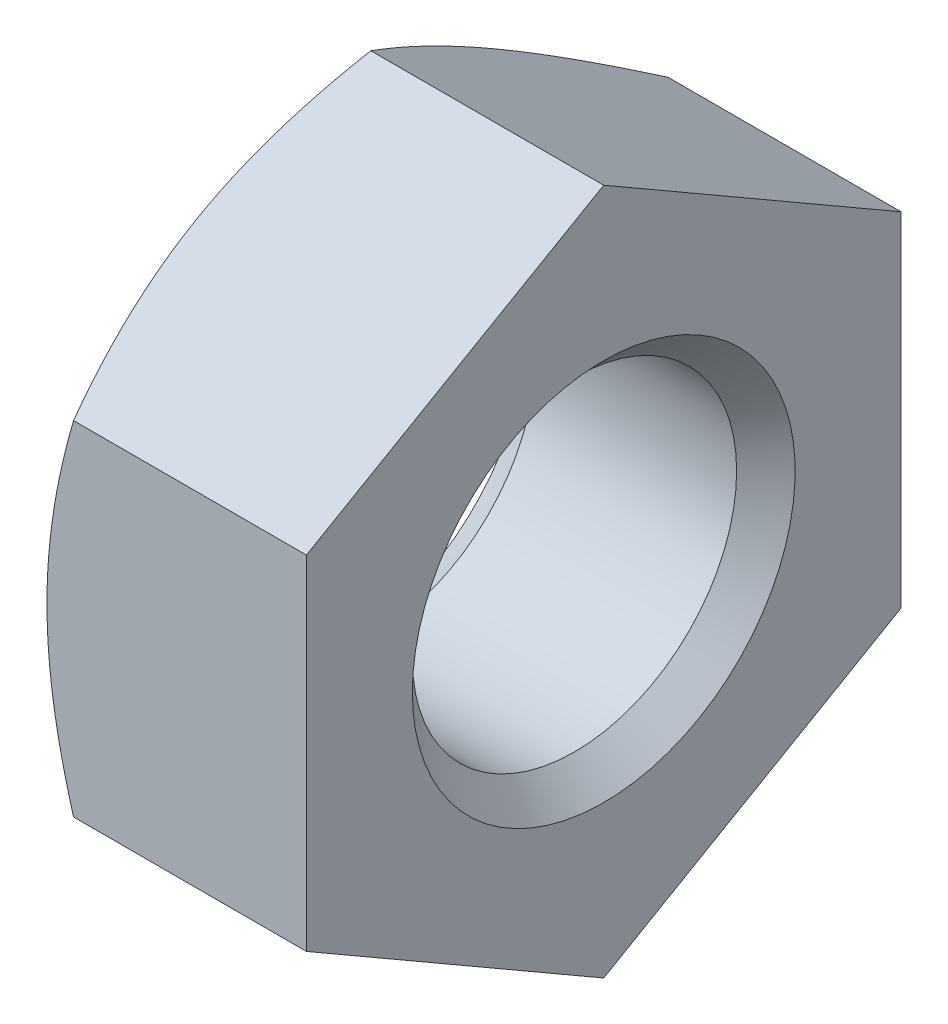
from build123d import *

# Parameters (mm, degrees)
CUT_EXTRUDE1_DEPTH      = 1.2
CUT_EXTRUDE1_DEPTH_BACK = 1.2
SKETCH3_W               = 11
SKETCH3_H               = 11


with BuildPart() as part:
    # Sketch1 → Revolve1 (revolve)
    with BuildSketch(Plane.XY):
        Polygon((-1.2, 0), (-1.2, 2.75), (-0.940192379, 3.2), (1.2, 3.2), (1.2, 0), align=None)
    revolve(axis=Axis((1.2, 0, 0), (-1, 0, 0)))

    # Sketch2 → Cut-Revolve1 (revolve, cut)
    with BuildSketch(Plane.XY):
        Polygon((-1.2, 0), (-1.2, 1.7), (-0.9295, 1.5), (0.9295, 1.5), (1.2, 1.7705), (1.2, 0), align=None)
    revolve(axis=Axis((1.2, 0, 0), (-1, 0, 0)), mode=Mode.SUBTRACT)

    # Sketch3 → Cut-Extrude1 (cut, two sides: drawn at the far end of the back side and taken through both)
    with BuildSketch(Plane(origin=(0, 0, 0), x_dir=(0, 0, -1), z_dir=(1, 0, 0)).offset(-CUT_EXTRUDE1_DEPTH_BACK)):
        Rectangle(SKETCH3_W, SKETCH3_H)
        Polygon((-2.75, -1.58771324), (0, -3.175426481), (2.75, -1.58771324), (2.75, 1.58771324), (0, 3.175426481), (-2.75, 1.58771324), align=None, mode=Mode.SUBTRACT)
    extrude(amount=CUT_EXTRUDE1_DEPTH + CUT_EXTRUDE1_DEPTH_BACK, mode=Mode.SUBTRACT)


solid = part.part
